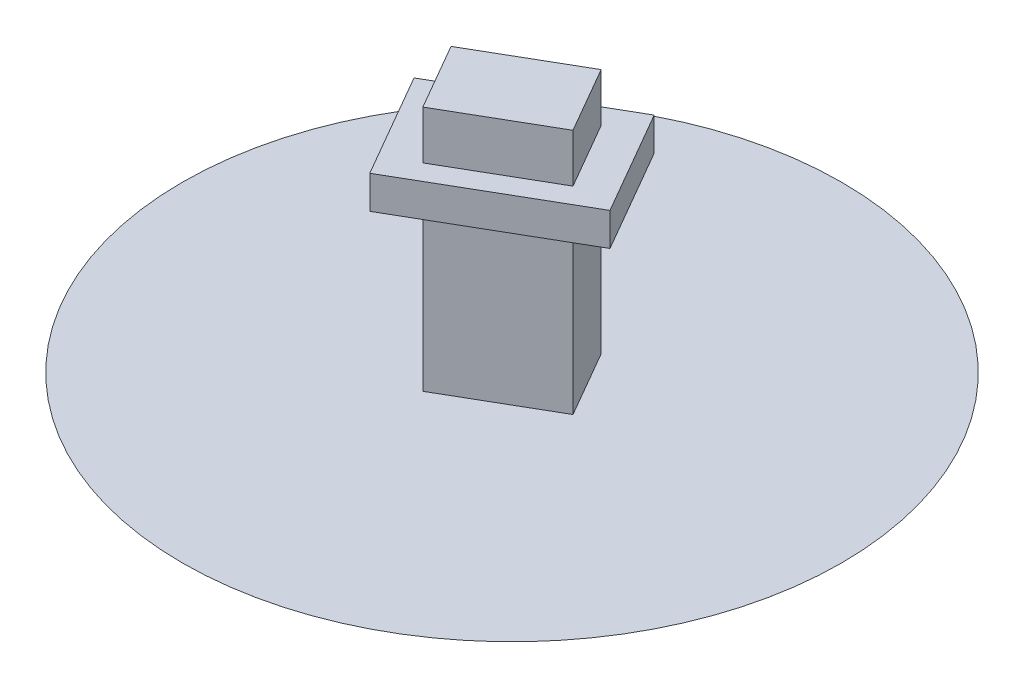
from build123d import *

# Parameters (mm, degrees)
EXTRUDE1_DEPTH = 15000
EXTRUDE2_DEPTH = 3000
EXTRUDE3_DEPTH = 4400
SKETCH4_R      = 30000
EXTRUDE4_DEPTH = 0.01


with BuildPart() as part:
    # Sketch1 → Extrude1 (new body)
    with BuildSketch(Plane(origin=(0, 0, 0), x_dir=(1, 0, 0), z_dir=(0, 1, 0))):
        Polygon((0, 0), (-8660.254037844, -5000), (-5160.254037844, -11062.177826491), (3500, -6062.177826491), align=None)
    extrude(amount=EXTRUDE1_DEPTH)

    # Sketch2 → Extrude2 (add)
    with BuildSketch(Plane(origin=(0, 15000, 0), x_dir=(-1, 0, 0), z_dir=(0, 1, 0))):
        Polygon((12258.330249198, 4767.949192431), (-1598.076211353, -3232.050807569), (-7098.076211353, 6294.22863406), (6758.330249198, 14294.22863406), align=None)
    extrude(amount=EXTRUDE2_DEPTH)

    # Sketch3 → Extrude3 (add)
    with BuildSketch(Plane(origin=(0, 18000, 0), x_dir=(-1, 0, 0), z_dir=(0, 1, 0))):
        Polygon((0, 0), (-3500, 6062.177826491), (5160.254037844, 11062.177826491), (8660.254037844, 5000), align=None)
    extrude(amount=EXTRUDE3_DEPTH)

    # Sketch4 → Extrude4 (add)
    with BuildSketch(Plane(origin=(0, 0, 0), x_dir=(1, 0, 0), z_dir=(0, 1, 0))):
        with Locations(Location((-2580.127018922, -5531.088913246, 0), (0, 0, 270))):  # turned: the seam where the file's is
            Circle(SKETCH4_R)
    extrude(amount=EXTRUDE4_DEPTH)


solid = part.part
